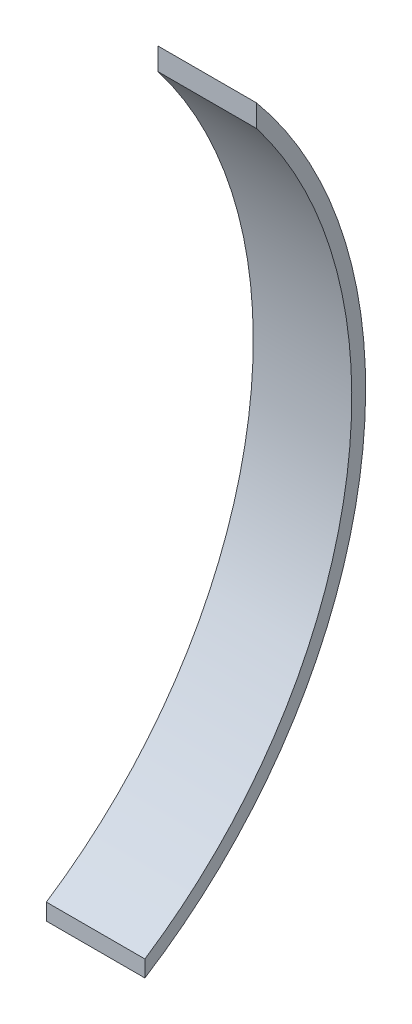
from build123d import *

# Parameters (mm, degrees)
EXTRUDE_1_DEPTH = 30


with BuildPart() as part:
    # 草图1 → 凸台-拉伸1 (new body)
    with BuildSketch(Plane(origin=(0, 0, 0), x_dir=(0, 0, -1), z_dir=(1, 0, 0))):
        with BuildLine():
            Line((0, -147.565704378), (0, -152.588372425))
            ThreePointArc((0, -152.588372425), (65.437410897, -53.399502568), (34, 61.196203479))
            Line((34, 61.196203479), (34, 54.434295622))
            ThreePointArc((34, 54.434295622), (61.061815881, -53.982049625), (0, -147.565704378))
        make_face()
    extrude(amount=EXTRUDE_1_DEPTH)


solid = part.part
